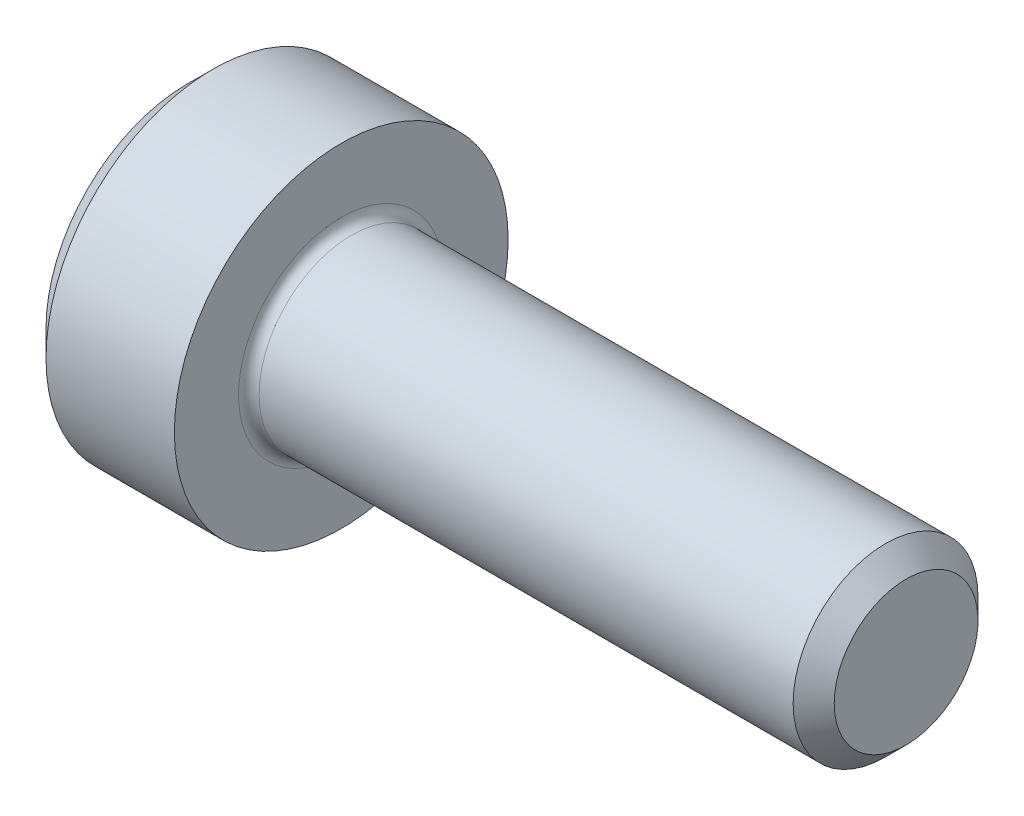
from build123d import *

# Parameters (mm, degrees)
FILLET1_R   = 0.2
HEX_2_DEPTH = 2.5


with BuildPart() as part:
    # BodySke → Base-Revolve (revolve)
    with BuildSketch(Plane.XY):
        Polygon((0, 0), (0, 2.75), (0.5, 3.25), (3, 3.25), (3, 1.8), (13.6, 1.8), (14, 1.4), (14, 0), align=None)
    revolve(axis=Axis((-31.75, 0, 0), (1, 0, 0)))

    # Fillet1
    fillet1_edges = [part.edges().sort_by_distance(p)[0] for p in [
        (3, -1.8, 0),
    ]]
    fillet(fillet1_edges, radius=FILLET1_R)

    # Sketch2 → Hex-PreBroach (revolve, cut)
    with BuildSketch(Plane.XY):
        Polygon((0, 1.6), (2.5, 1.6), (3.423760431, 0), (0, 0), align=None)
    revolve(axis=Axis((0, 0, 0), (1, 0, 0)), mode=Mode.SUBTRACT)

    # Sketch3 → Hex 2 (cut)
    with BuildSketch(Plane(origin=(0, 0, 0), x_dir=(0, 0.5, 0.866025404), z_dir=(-1, 0, 0))):
        Polygon((0.923760431, 1.6), (-0.923760431, 1.6), (-1.847520861, 0), (-0.923760431, -1.6), (0.923760431, -1.6), (1.847520861, 0), align=None)
    extrude(amount=-HEX_2_DEPTH, mode=Mode.SUBTRACT)


solid = part.part
